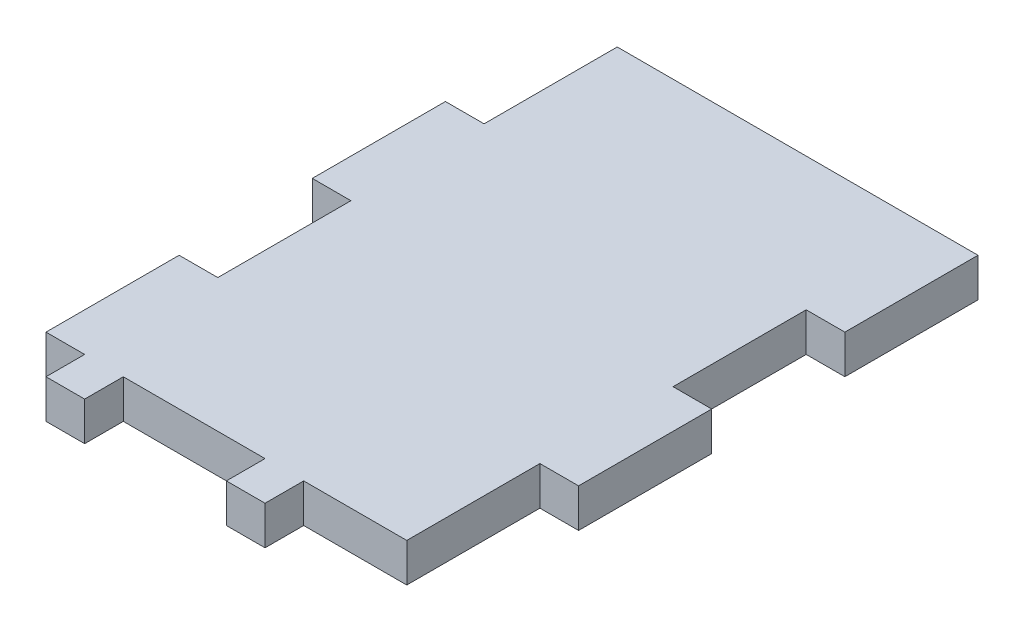
from build123d import *

# Parameters (mm, degrees)
BOSS_EXTRUDE1_DEPTH = 4.5


with BuildPart() as part:
    # Sketch1 → Boss-Extrude1 (new body)
    with BuildSketch(Plane(origin=(0, 0, 0), x_dir=(1, 0, 0), z_dir=(0, 1, 0))):
        Polygon((-21, 0), (-21, -15.5), (-25.5, -15.5), (-25.5, -31), (-21, -31), (-21, -35.5), (-16.5, -35.5), (-16.5, -31), (0, -31), (0, -35.5), (4.5, -35.5), (4.5, -31), (16.5, -31), (16.5, -15.5), (21, -15.5), (21, 0), (16.5, 0), (16.5, 15.5), (21, 15.5), (21, 31), (-21, 31), (-21, 15.5), (-25.5, 15.5), (-25.5, 0), align=None)
    extrude(amount=BOSS_EXTRUDE1_DEPTH)


solid = part.part
